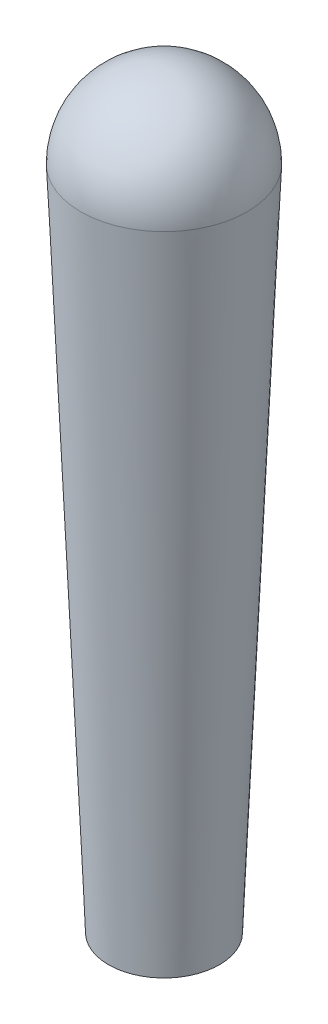
from build123d import *

# Parameters (mm, degrees)
SKETCH1_R = 1
SKETCH2_R = 1.5


with BuildPart() as part:
    # Sketch1 → Loft1 section 0
    with BuildSketch(Plane(origin=(0, 0, 0), x_dir=(1, 0, 0), z_dir=(0, 1, 0))):
        Circle(SKETCH1_R)
    # Sketch2 → Loft1 section 1
    with BuildSketch(Plane(origin=(0, 12, 0), x_dir=(1, 0, 0), z_dir=(0, 1, 0))):
        Circle(SKETCH2_R)
    loft()

    # Sketch3 → Revolve1 (revolve)
    with BuildSketch(Plane.XY):
        with BuildLine():
            Line((0, 12), (1.5, 12))
            ThreePointArc((1.5, 12), (1.060660172, 13.060660172), (0, 13.5))
            Line((0, 13.5), (0, 12))
        make_face()
    revolve(axis=Axis((0, 0, 0), (0, 1, 0)))


solid = part.part
